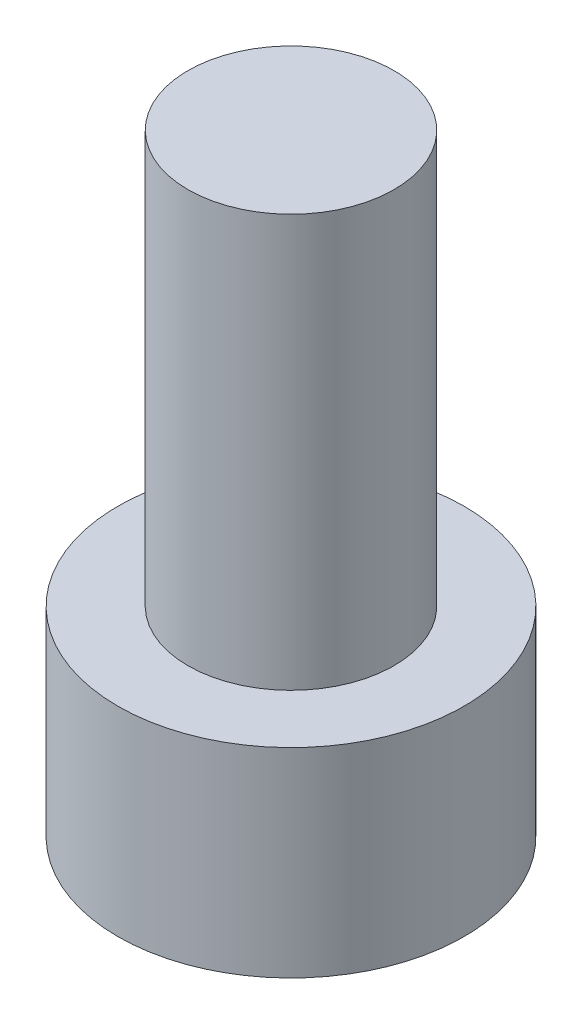
from build123d import *

# Parameters (mm, degrees)
SKETCH_1_R          = 4.2
EXTRUDE_1_DEPTH     = 4.84
SKETCH_2_R          = 2.5
EXTRUDE_2_DEPTH     = 10
CUT_EXTRUDE_1_DEPTH = 3.4


with BuildPart() as part:
    # 草图1 → 凸台-拉伸1 (new body)
    with BuildSketch(Plane(origin=(0, 0, 0), x_dir=(1, 0, 0), z_dir=(0, 1, 0))):
        Circle(SKETCH_1_R)
    extrude(amount=EXTRUDE_1_DEPTH)

    # 草图2 → 凸台-拉伸2 (add)
    with BuildSketch(Plane(origin=(0, 4.84, 0), x_dir=(1, 0, 0), z_dir=(0, 1, 0))):
        Circle(SKETCH_2_R)
    extrude(amount=EXTRUDE_2_DEPTH)

    # 草图3 → 切除-拉伸1 (cut)
    with BuildSketch(Plane.XZ):
        Polygon((2.3, 0), (1.15, 1.991858429), (-1.15, 1.991858429), (-2.3, 0), (-1.15, -1.991858429), (1.15, -1.991858429), align=None)
    extrude(amount=-CUT_EXTRUDE_1_DEPTH, mode=Mode.SUBTRACT)


solid = part.part
